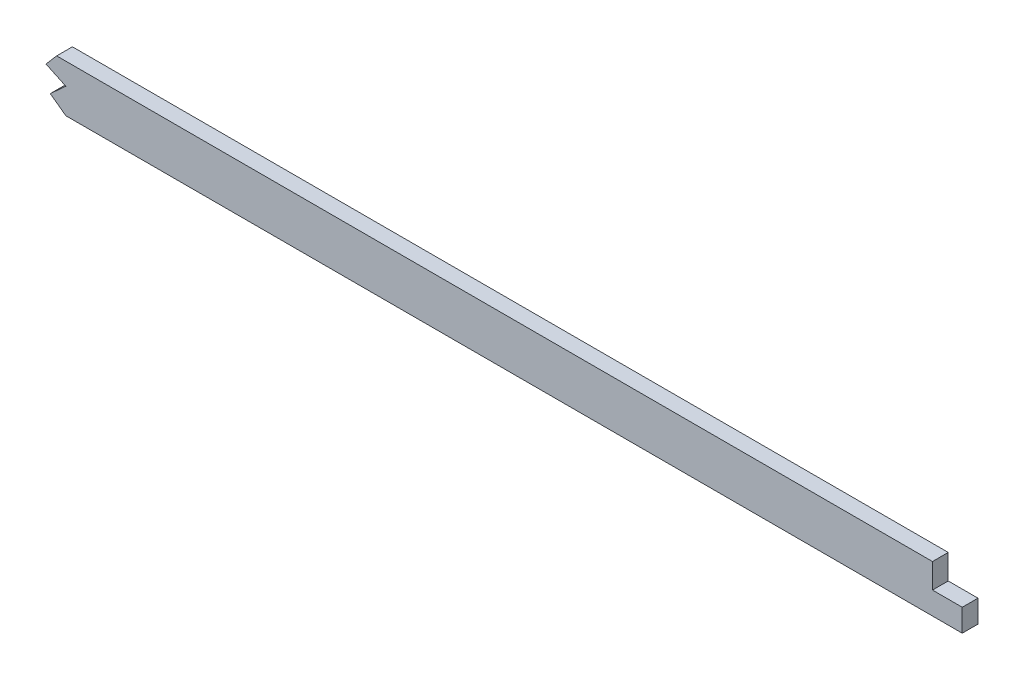
from build123d import *

# Parameters (mm, degrees)
BOSS_EXTRUDE1_DEPTH = 3.175
CUT_EXTRUDE1_DEPTH  = 7.3500001
FILLET1_R           = 2.54
CUT_EXTRUDE2_DEPTH  = 7.62


with BuildPart() as part:
    # Sketch1 → Boss-Extrude1 (new body, symmetric)
    with BuildSketch(Plane.XY):
        with BuildLine():
            Line((499.61002795, -53.470702797), (1046.28548189, -53.470702797))
            add(Edge.make_bspline(
                [(2669.54, -9.569049356), (2615.393603553, -13.17073937), (2561.080658619, -16.536108081), (2506.205230446, -19.758621957), (2430.209106802, -23.505211705), (2354.212983157, -26.631486423), (2332.570330468, -27.480988169), (2156.268639429, -34.377768543), (1979.966947376, -41.628631248), (1824.114277635, -52.771265877), (1636.928606778, -53.579569849), (1449.742935921, -53.454024613), (1418.006730935, -53.470702797), (1324.899336146, -53.470702797), (1231.791940344, -53.470702797), (1170.441269319, -53.470702797), (1108.784075813, -53.470702797), (1047.126882346, -53.470702797), (1046.846414188, -53.470702797), (1046.565947184, -53.470702797), (1046.28548189, -53.470702797)],
                knots=[103.698913506, 103.698913506, 103.698913506, 103.698913506, 103.698913506, 103.698913506, 130.927896619, 130.927896619, 130.927896619, 141.337054719, 141.337054719, 141.337054719, 218.101815019, 218.101815019, 218.101815019, 233.772059419, 233.772059419, 233.772059419, 264.077723219, 264.077723219, 264.077723219, 264.2162088, 264.2162088, 264.2162088, 264.2162088, 264.2162088, 264.2162088], degree=5))
            Line((2669.54, -9.569049356), (2669.54, 9.5231025))
            add(Edge.make_bspline(
                [(2669.54, 9.5231025), (2667.126494524, 9.36235515), (2659.861586685, 8.880281494), (2635.666282302, 7.292469146), (2596.857665529, 4.826056853), (2545.729743039, 1.758344093), (2494.405305707, -1.098555235), (2451.533022267, -3.266573297), (2417.198316756, -4.86708361), (2391.457076919, -6.003589235), (2365.634736307, -7.086854581), (2339.546284672, -8.137729944), (2313.466132974, -9.165138371), (2287.612375486, -10.179478215), (2261.763347437, -11.201032297), (2227.285329715, -12.583842557), (2184.175569393, -14.36607236), (2132.429066114, -16.607427868), (2063.4255234, -19.708920485), (1977.174907635, -23.700543313), (1873.732451432, -28.149389221), (1770.37461881, -31.657468649), (1667.085687813, -33.793117556), (1581.011094491, -34.383188831), (1512.07397126, -34.4278026), (1443.061513477, -34.409510402), (1356.800927879, -34.424432812), (1218.794626954, -34.418464788), (1115.289022786, -34.420702797), (1046.28548189, -34.420702797)],
                knots=[103.571582669, 103.571582669, 103.571582669, 103.571582669, 104.300777207, 105.766098403, 110.877392287, 115.98868617, 121.099980054, 126.211273938, 128.76692088, 131.322567822, 133.878214764, 136.433861706, 138.989508647, 141.545155589, 144.100802531, 146.656449473, 151.767743357, 156.879037241, 161.990331124, 172.212918892, 182.43550666, 192.658094427, 202.880682195, 213.103269962, 218.214563846, 223.32585773, 233.548445497, 243.771033265, 264.2162088, 264.2162088, 264.2162088, 264.2162088], degree=3))
            Line((1046.28548189, -34.420702797), (499.61002795, -34.420702797))
            add(Edge.make_bspline(
                [(499.61002795, -34.420702797), (488.614737518, -34.420702797), (472.236395365, -34.420702798), (449.940231846, -34.420702794), (427.771305695, -34.42070281), (405.874681663, -34.420702712), (384.584909128, -34.420702942), (368.900229326, -34.420702244), (353.376568613, -34.420704862), (332.608466435, -34.420689186), (306.287754853, -34.420570006), (274.023487704, -34.420538256), (252.271015965, -34.420709741), (241.425150134, -34.420702761)],
                knots=[19.90682951, 19.90682951, 19.90682951, 19.90682951, 23.220120017, 24.876765271, 26.533410525, 29.846701033, 31.503346286, 33.15999154, 34.816636794, 36.473282048, 39.786572556, 43.099863063, 46.413153571, 46.413153571, 46.413153571, 46.413153571], degree=3))
            add(Edge.make_bspline(
                [(241.425150134, -34.420702761), (239.394928853, -34.420701455), (235.322322927, -34.420495867), (227.274423443, -34.398702533), (217.319360062, -34.297466855), (205.530690077, -33.976385563), (189.963341914, -33.212641271), (170.696984653, -31.543495194), (147.533261232, -28.314398128), (125.482753206, -24.202109872), (109.358914834, -20.622537553), (100.964116069, -18.612521054), (99.06, -18.149327722)],
                knots=[0, 0, 0, 0, 0.622088422, 1.244176844, 2.488353689, 3.732530533, 4.976707377, 7.465061066, 9.953414755, 12.441768444, 14.55823542, 15.180323842, 15.180323842, 15.180323842, 15.180323842], degree=3))
            Line((99.06, -18.149327722), (99.06, -37.741485304))
            add(Edge.make_bspline(
                [(241.425137875, -53.470702761), (224.286916993, -53.470691732), (207.149474967, -53.467315374), (190.203897513, -52.686577078), (161.734965878, -49.987457476), (133.266034188, -45.175583375), (121.749620566, -42.910592695), (110.349390726, -40.420274627), (99.06, -37.741485304)],
                knots=[0, 0, 0, 0, 0, 0, 8.71381608, 8.71381608, 8.71381608, 14.701907176, 14.701907176, 14.701907176, 14.701907176, 14.701907176, 14.701907176], degree=5))
            add(Edge.make_bspline(
                [(499.61002795, -53.470702797), (492.136820835, -53.470702797), (484.754348064, -53.470702797), (477.443025859, -53.470702797), (448.516583145, -53.470702797), (419.590140517, -53.470702797), (398.368118521, -53.470702797), (355.647540186, -53.470702797), (312.926961851, -53.470702797), (289.235090436, -53.470293029), (265.364963651, -53.470705034), (241.4948369, -53.470702789), (241.471603891, -53.470702785), (241.448370882, -53.470702776), (241.425137875, -53.470702761)],
                knots=[19.90682951, 19.90682951, 19.90682951, 19.90682951, 19.90682951, 19.90682951, 23.637897311, 23.637897311, 23.637897311, 34.276545571, 34.276545571, 34.276545571, 46.401340901, 46.401340901, 46.401340901, 46.413153571, 46.413153571, 46.413153571, 46.413153571, 46.413153571, 46.413153571], degree=5))
        make_face()
    extrude(amount=BOSS_EXTRUDE1_DEPTH, both=True)

    # Sketch2 → Cut-Extrude1 (cut, through all)
    with BuildSketch(Plane.XY.offset(3.175)):
        with BuildLine():
            add(Edge.make_bspline(
                [(2312.9875, -9.183260037), (2304.505441691, -9.516700376), (2287.441020622, -10.186250162), (2261.763347437, -11.201032297), (2228.230552004, -12.545932515), (2203.310445107, -13.575047161), (2187.00995947, -14.263260037)],
                knots=[139.04033329, 139.04033329, 139.04033329, 139.04033329, 141.545155589, 144.100802531, 146.656449473, 151.487488909, 151.487488909, 151.487488909, 151.487488909], degree=3))
            Line((2187.00995947, -14.263260037), (2312.9875, -14.263260037))
            Line((2312.9875, -14.263260037), (2312.9875, -9.183260037))
        make_face()
    extrude(amount=-CUT_EXTRUDE1_DEPTH, mode=Mode.SUBTRACT)

    # Fillet1
    fillet1_edges = [part.edges().sort_by_distance(p)[0] for p in [
        (2669.54, -9.569049356, -1.5875),
        (2669.54, 9.5231025, -1.5875),
        (99.06, -37.741485304, -1.5875),
        (99.06, -18.149327722, -1.5875),
        (2312.9875, -9.183260037, 1.5875),
        (2312.9875, -14.263260037, 0),
    ]]
    fillet(fillet1_edges, radius=FILLET1_R)

    # Sketch3 → Cut-Extrude2 (cut)
    with BuildSketch(Plane.XY.offset(3.175)):
        Polygon((1181.433983433, -34.420040525), (1177.136382458, -39.41105826), (1185.135968065, -43.161373269), (1178.857838528, -48.879066642), (1185.135968065, -53.470702797), (1185.135968065, -76.771212746), (0, -269.970579329), (-115.576123812, 193.994123709), (1181.433983433, 141.355355937), align=None)
        Polygon((1534.520918045, -34.408934174), (1534.520918045, -44.380222694), (1546.518002564, -44.380222694), (1546.518002564, -53.444776375), (1547.50690107, -59.06466964), (2722.698551589, -126.981023112), (2732.810767707, 122.182227989), (1534.520918045, 141.355355937), align=None)
    extrude(amount=-CUT_EXTRUDE2_DEPTH, mode=Mode.SUBTRACT)


solid = part.part
